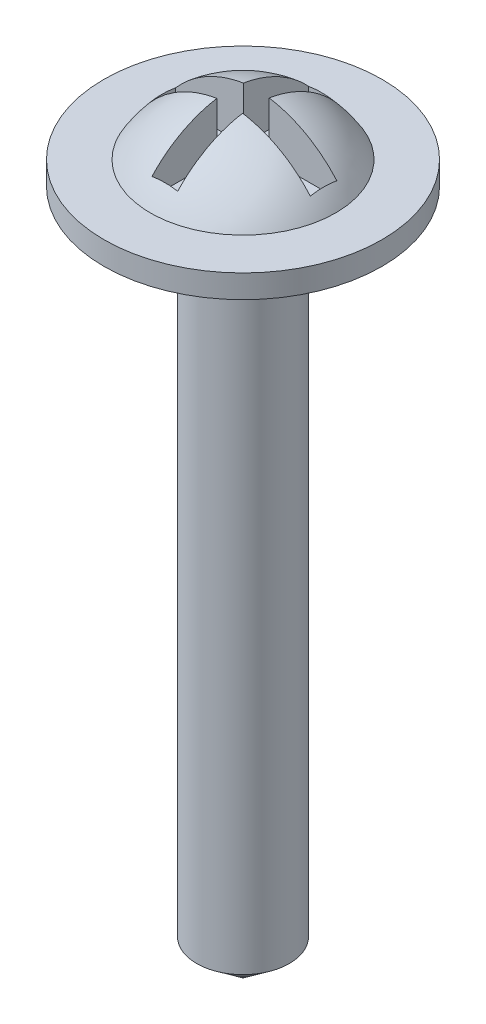
from build123d import *

# Parameters (mm, degrees)
CUT_EXTRUDE1_DEPTH = 10


with BuildPart() as part:
    # Sketch1 → Revolve1 (revolve)
    with BuildSketch(Plane(origin=(0, 0, 0), x_dir=(0, 0, -1), z_dir=(1, 0, 0))):
        with BuildLine():
            Line((0, 0), (0, 16.5))
            ThreePointArc((0, 16.5), (-1.148517206, 16.147528677), (-2, 15.3))
            Line((-2, 15.3), (-3, 15.3))
            Line((-3, 15.3), (-3, 14.8))
            Line((-3, 14.8), (-1, 14.8))
            Line((-1, 14.8), (-1, 0.769364806))
            Line((-1, 0.769364806), (0, 0))
        make_face()
    revolve(axis=Axis((0, 0, 0), (0, 1, 0)))

    # Sketch2 → Cut-Extrude1 (cut)
    with BuildSketch(Plane(origin=(0, 15.3, 0), x_dir=(1, 0, 0), z_dir=(0, 1, 0))):
        Polygon((0.277999407, -1.686950947), (-0.277999407, -1.686950947), (-0.277999407, -0.28662128), (-1.73927004, -0.28662128), (-1.73927004, 0.28662128), (-0.277999407, 0.28662128), (-0.277999407, 1.686950947), (0.277999407, 1.686950947), (0.277999407, 0.28662128), (1.73927004, 0.28662128), (1.73927004, -0.28662128), (0.277999407, -0.28662128), align=None)
    extrude(amount=CUT_EXTRUDE1_DEPTH, mode=Mode.SUBTRACT)


solid = part.part
